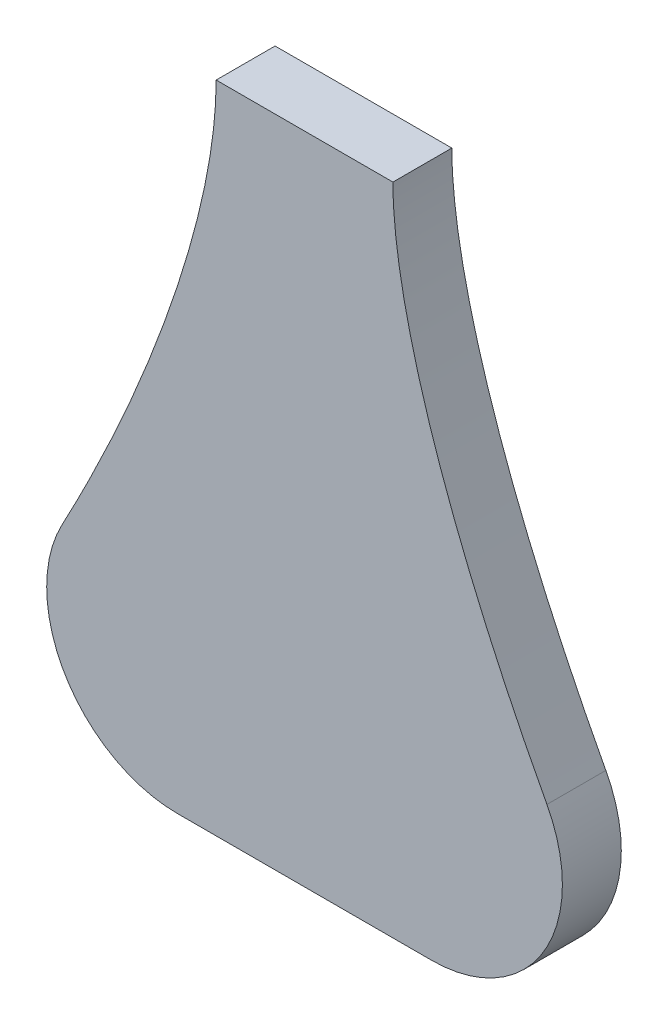
from build123d import *

# Parameters (mm, degrees)
BOSS_EXTRUDE1_DEPTH = 18
FILLET1_R           = 40


with BuildPart() as part:
    # Sketch1 → Boss-Extrude1 (new body)
    with BuildSketch(Plane.XY):
        with BuildLine():
            Line((-27, 0), (27, 0))
            add(Edge.make_bspline(
                [(27, 0), (27, -49.026425591), (64.594351551, -134.908704781), (110, -200)],
                knots=[0, 0, 0, 0, 1, 1, 1, 1], degree=3))
            Line((110, -200), (-110, -200))
            add(Edge.make_bspline(
                [(-27, 0), (-27, -49.026425591), (-64.594351551, -134.908704781), (-110, -200)],
                knots=[0, 0, 0, 0, 1, 1, 1, 1], degree=3))
        make_face()
    extrude(amount=BOSS_EXTRUDE1_DEPTH)

    # Fillet1
    fillet1_edges = [part.edges().sort_by_distance(p)[0] for p in [
        (-110, -200, 9),
        (110, -200, 9),
    ]]
    fillet(fillet1_edges, radius=FILLET1_R)


solid = part.part
